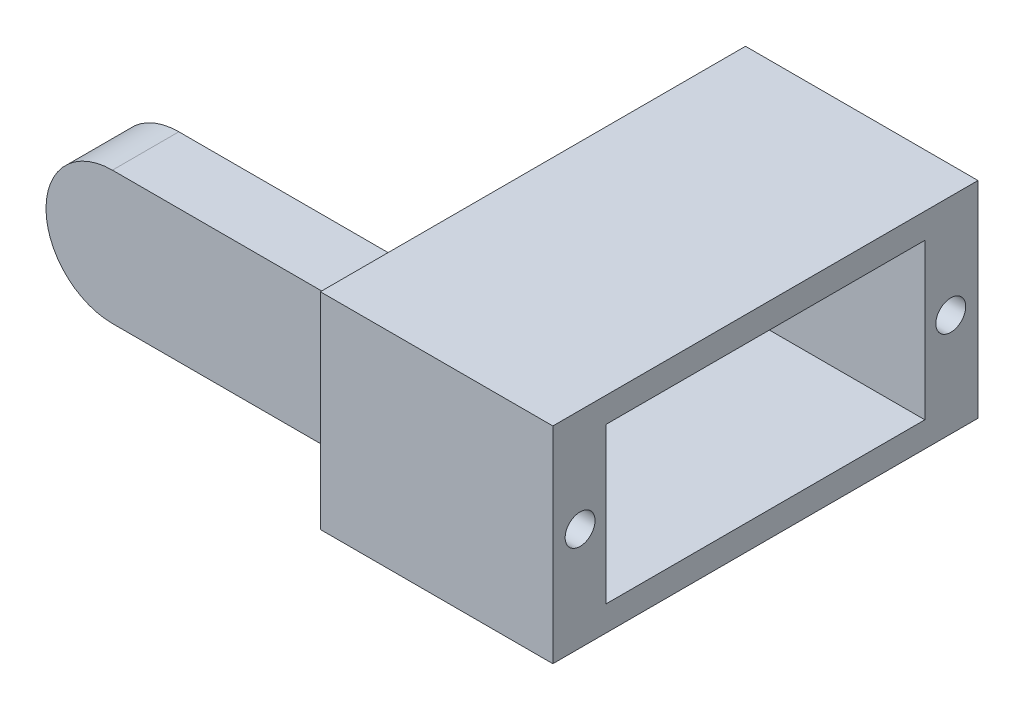
from build123d import *

# Parameters (mm, degrees)
BOSS_EXTRUDE1_DEPTH = 5
SKETCH2_R           = 2.35
CUT_EXTRUDE1_DEPTH  = 3
SKETCH3_W           = 32
SKETCH3_H           = 15.5
SKETCH3_W_2         = 5
SKETCH3_H_2         = 10
BOSS_EXTRUDE2_DEPTH = 2.4
SKETCH4_W           = 32
SKETCH4_H           = 15.5
SKETCH4_W_2         = 24
SKETCH4_H_2         = 11.7
BOSS_EXTRUDE3_DEPTH = 15.1
SKETCH6_R           = 1.125
CUT_EXTRUDE2_DEPTH  = 8


with BuildPart() as part:
    # Sketch1 → Boss-Extrude1 (new body)
    with BuildSketch(Plane.XY):
        with BuildLine():
            Line((0, 5), (20.9, 5))
            Line((20.9, 5), (20.9, -5))
            Line((20.9, -5), (0, -5))
            ThreePointArc((0, -5), (-5, 0), (0, 5))
        make_face()
    extrude(amount=BOSS_EXTRUDE1_DEPTH)

    # Sketch2 → Cut-Extrude1 (cut)
    with BuildSketch(Plane(origin=(0, 0, 0), x_dir=(-1, 0, 0), z_dir=(0, 0, -1))):
        Circle(SKETCH2_R)
    extrude(amount=-CUT_EXTRUDE1_DEPTH, mode=Mode.SUBTRACT)

    # Sketch3 → Boss-Extrude2 (add)
    with BuildSketch(Plane(origin=(20.9, 0, 0), x_dir=(0, 0, -1), z_dir=(1, 0, 0))):
        with Locations((8.15, 0)):
            Rectangle(SKETCH3_W, SKETCH3_H)
        with Locations((-2.5, 0)):
            Rectangle(SKETCH3_W_2, SKETCH3_H_2, mode=Mode.SUBTRACT)
    extrude(amount=-BOSS_EXTRUDE2_DEPTH)

    # Sketch4 → Boss-Extrude3 (add)
    with BuildSketch(Plane(origin=(20.9, 0, 0), x_dir=(0, 0, -1), z_dir=(1, 0, 0))):
        with Locations((8.15, 0)):
            Rectangle(SKETCH4_W, SKETCH4_H)
        with Locations((8.15, 0)):
            Rectangle(SKETCH4_W_2, SKETCH4_H_2, mode=Mode.SUBTRACT)
    extrude(amount=BOSS_EXTRUDE3_DEPTH)

    # Sketch6 → Cut-Extrude2 (cut)
    with BuildSketch(Plane(origin=(36, 0, 0), x_dir=(0, 0, -1), z_dir=(1, 0, 0))):
        with Locations((-5.8, 0)):
            Circle(SKETCH6_R)
        with Locations((22.1, 0)):
            Circle(SKETCH6_R)
    extrude(amount=-CUT_EXTRUDE2_DEPTH, mode=Mode.SUBTRACT)


solid = part.part
